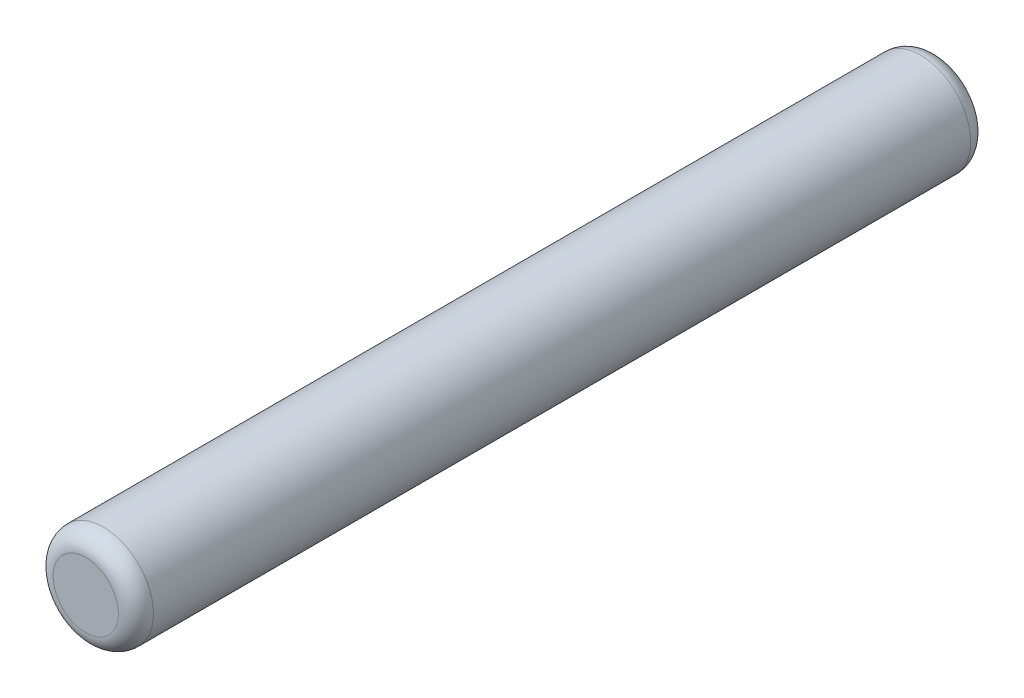
from build123d import *

# Parameters (mm, degrees)
SKETCH1_R           = 1
BOSS_EXTRUDE1_DEPTH = 8.5
FILLET1_R           = 0.35


with BuildPart() as part:
    # Sketch1 → Boss-Extrude1 (new body, symmetric)
    with BuildSketch(Plane.XY):
        Circle(SKETCH1_R)
    extrude(amount=BOSS_EXTRUDE1_DEPTH, both=True)

    # Fillet1
    fillet1_edges = [part.edges().sort_by_distance(p)[0] for p in [
        (-1, 0, -8.5),
        (-1, 0, 8.5),
    ]]
    fillet(fillet1_edges, radius=FILLET1_R)


solid = part.part
